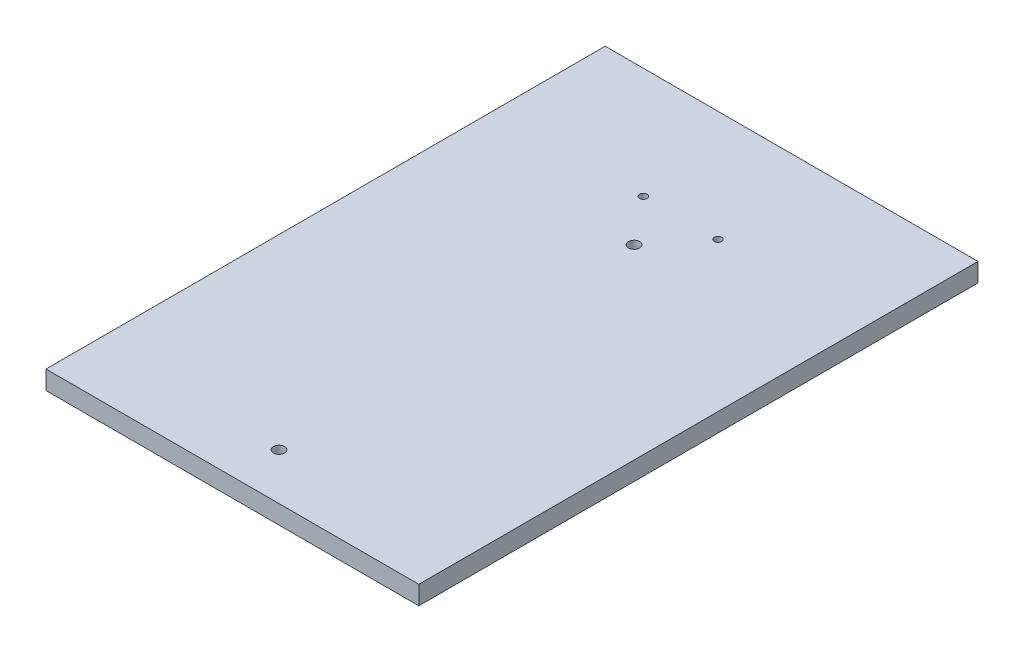
from build123d import *

# Parameters (mm, degrees)
IZIM1_W                     = 200
IZIM1_H                     = 300
Y_KSEKLIK_EKSTR_ZYON1_DEPTH = 10
IZIM2_R                     = 3
IZIM2_R_2                   = 2
KES_EKSTR_ZYON1_DEPTH       = 10


with BuildPart() as part:
    # Çizim1 → Yükseklik-Ekstrüzyon1 (new body)
    with BuildSketch(Plane(origin=(0, 0, 0), x_dir=(1, 0, 0), z_dir=(0, 1, 0))):
        Rectangle(IZIM1_W, IZIM1_H)
    extrude(amount=Y_KSEKLIK_EKSTR_ZYON1_DEPTH)

    # Çizim2 → Kes-Ekstrüzyon1 (cut)
    with BuildSketch(Plane(origin=(0, 10, 0), x_dir=(1, 0, 0), z_dir=(0, 1, 0))):
        with Locations((0, -125)):
            Circle(IZIM2_R)
        with Locations((0, 65.5)):
            Circle(IZIM2_R)
        with Locations((-20, 90.5)):
            Circle(IZIM2_R_2)
        with Locations((20, 90.5)):
            Circle(IZIM2_R_2)
    extrude(amount=-KES_EKSTR_ZYON1_DEPTH, mode=Mode.SUBTRACT)


solid = part.part
